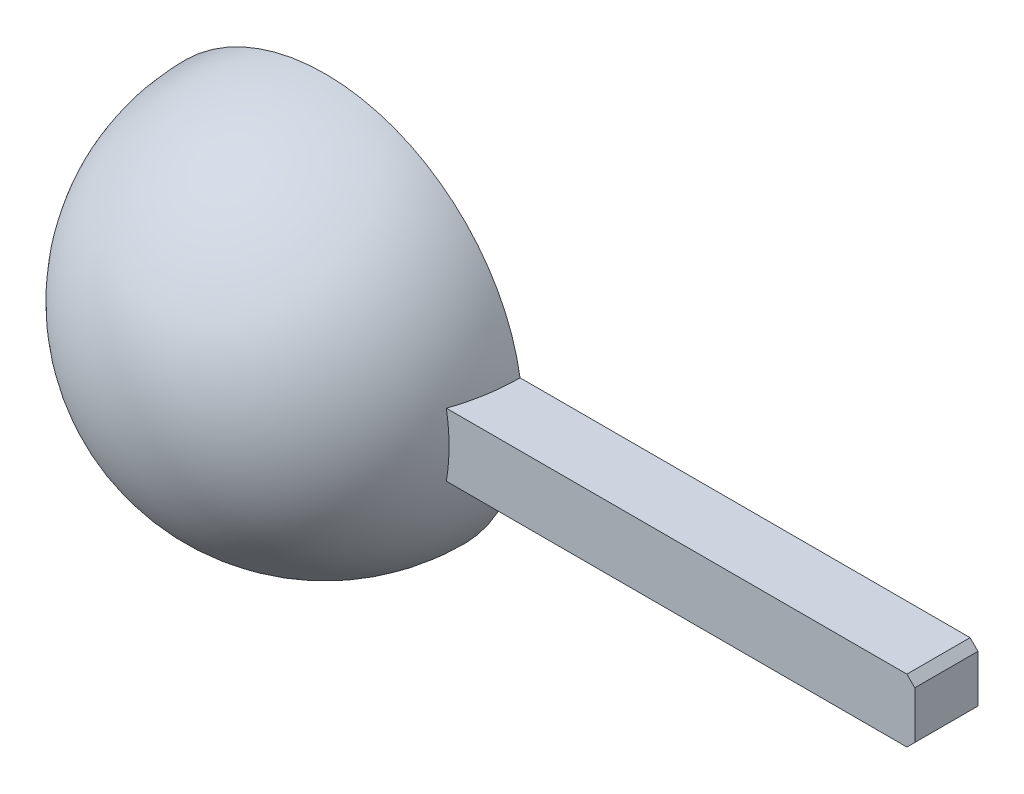
from build123d import *

# Parameters (mm, degrees)
R_VOLUTION1_ANGLE  = 180
COQUE1_T           = -2
ESQUISSE2_W        = 60
ESQUISSE2_H        = 8
BOSS_EXTRU_1_DEPTH = 8
CHANFREIN1_SIZE    = 1


with BuildPart() as part:
    # Esquisse1 → Révolution1 (revolve)
    with BuildSketch(Plane.XY):
        with BuildLine():
            Line((-25, 0), (25, 0))
            ThreePointArc((25, 0), (0, 25), (-25, 0))
        make_face()
    revolve(axis=Axis((-25, 0, 0), (1, 0, 0)), revolution_arc=R_VOLUTION1_ANGLE)

    # Coque1
    coque1_openings = [part.faces().sort_by_distance(p)[0] for p in [
        (-25, 0, 0),
    ]]
    offset(amount=COQUE1_T, openings=coque1_openings)

    # Esquisse2 → Boss.-Extru.1 (add)
    with BuildSketch(Plane.XY):
        with Locations((52.649503306, 0)):
            Rectangle(ESQUISSE2_W, ESQUISSE2_H)
    extrude(amount=BOSS_EXTRU_1_DEPTH)

    # Chanfrein1
    chanfrein1_edges = [part.edges().sort_by_distance(p)[0] for p in [
        (82.649503306, -4, 4),
        (82.649503306, 4, 4),
    ]]
    chamfer(chanfrein1_edges, length=CHANFREIN1_SIZE)


solid = part.part
